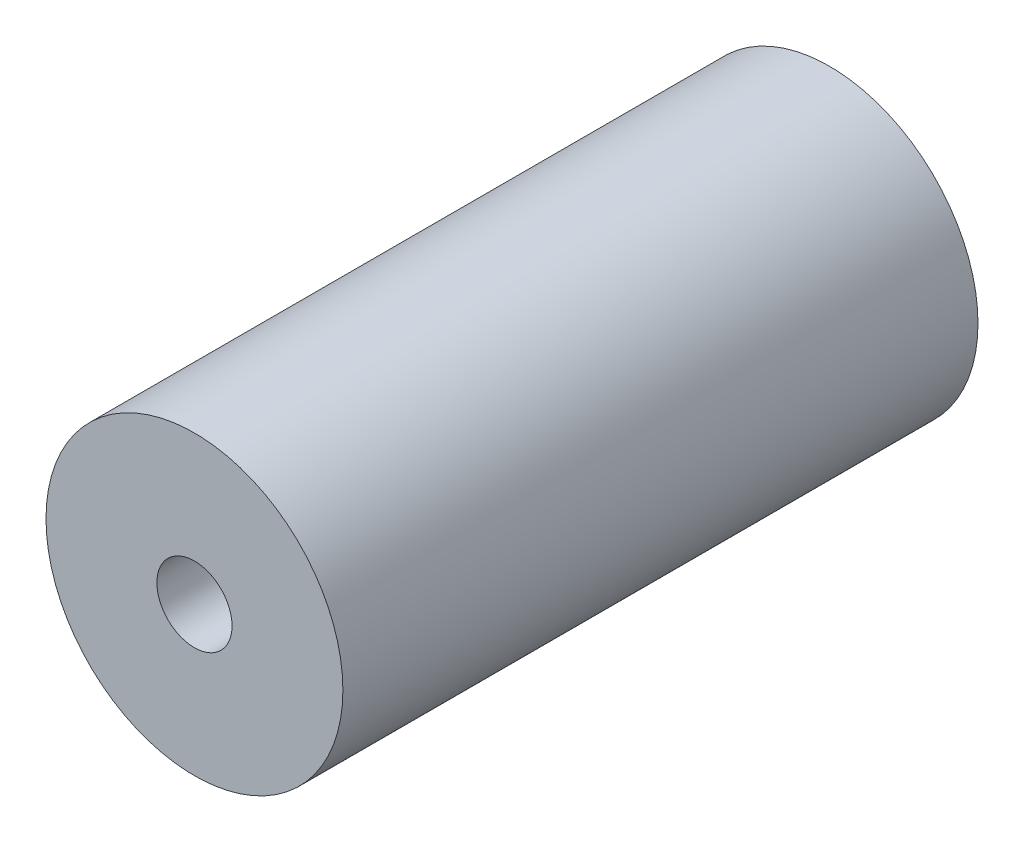
from build123d import *

# Parameters (mm, degrees)
SKETCH1_R           = 1.975
SKETCH1_R_2         = 0.5
BOSS_EXTRUDE1_DEPTH = 8.45


with BuildPart() as part:
    # Sketch1 → Boss-Extrude1 (new body)
    with BuildSketch(Plane.XY):
        Circle(SKETCH1_R)
        Circle(SKETCH1_R_2, mode=Mode.SUBTRACT)
    extrude(amount=BOSS_EXTRUDE1_DEPTH)


solid = part.part
